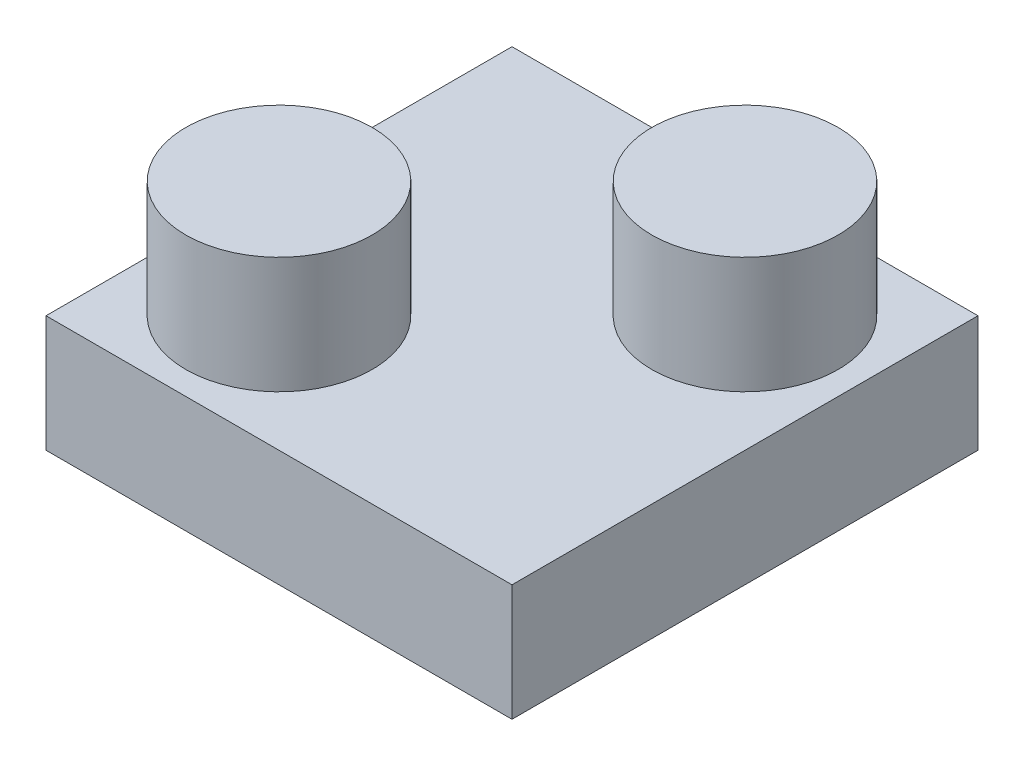
from build123d import *

# Parameters (mm, degrees)
SKETCH1_W           = 10
SKETCH1_H           = 10
BOSS_EXTRUDE1_DEPTH = 5
SKETCH2_W           = 10
SKETCH2_H           = 10
SKETCH2_R           = 2
CUT_EXTRUDE1_DEPTH  = 2.5


with BuildPart() as part:
    # Sketch1 → Boss-Extrude1 (new body)
    with BuildSketch(Plane(origin=(0, 0, 0), x_dir=(1, 0, 0), z_dir=(0, 1, 0))):
        Rectangle(SKETCH1_W, SKETCH1_H)
    extrude(amount=BOSS_EXTRUDE1_DEPTH)

    # Sketch2 → Cut-Extrude1 (cut)
    with BuildSketch(Plane(origin=(0, 5, 0), x_dir=(1, 0, 0), z_dir=(0, 1, 0))):
        Rectangle(SKETCH2_W, SKETCH2_H)
        with Locations((-2.5, -2.5)):
            Circle(SKETCH2_R, mode=Mode.SUBTRACT)
        with Locations((2.5, 2.5)):
            Circle(SKETCH2_R, mode=Mode.SUBTRACT)
    extrude(amount=-CUT_EXTRUDE1_DEPTH, mode=Mode.SUBTRACT)


solid = part.part
